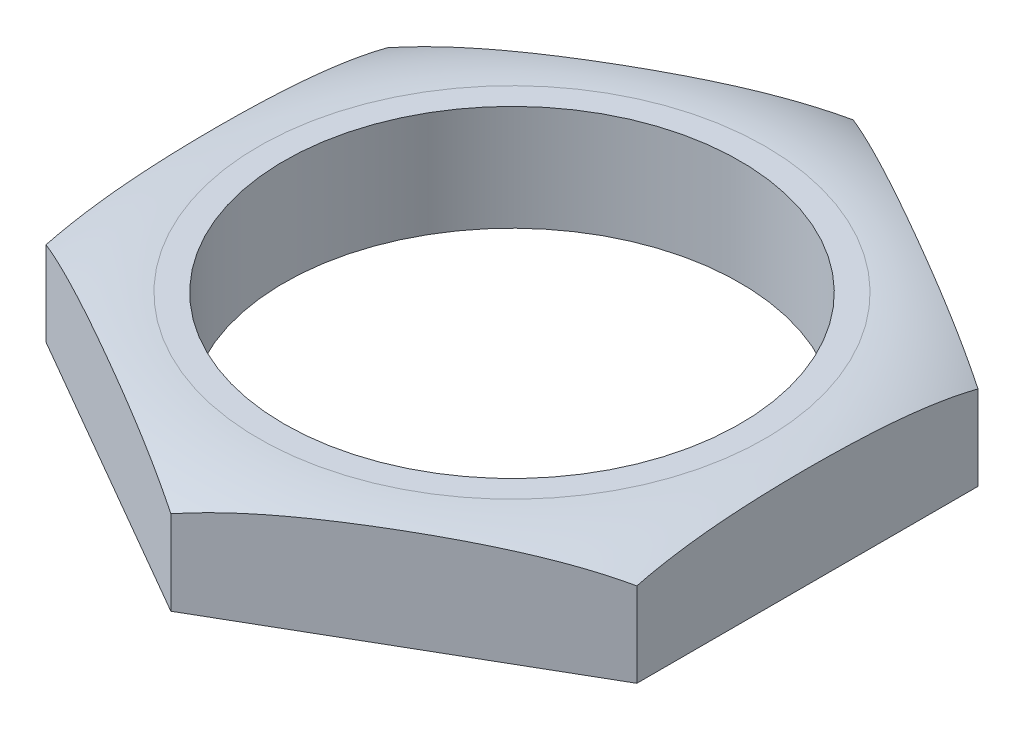
from build123d import *

# Parameters (mm, degrees)
EXTRUDE_1_DEPTH = 2.5
M12X1_252_D     = 10.8


with BuildPart() as part:
    # Эскиз1 → Бобышка-Вытянуть1 (new body)
    with BuildSketch(Plane(origin=(0, 0, 0), x_dir=(1, 0, 0), z_dir=(0, 1, 0))):
        Polygon((0, -8.082903769), (7, -4.041451884), (7, 4.041451884), (0, 8.082903769), (-7, 4.041451884), (-7, -4.041451884), align=None)
    extrude(amount=EXTRUDE_1_DEPTH)

    # Эскиз2 → Вырез-Повернуть1 (revolve, cut)
    with BuildSketch(Plane(origin=(0, 0, 0), x_dir=(0, 0, -1), z_dir=(1, 0, 0))):
        with BuildLine():
            Line((-8.082903769, 2.5), (-8.082903769, 2))
            ThreePointArc((-8.082903769, 2), (-7.071037827, 2.373249344), (-6, 2.5))
            Line((-6, 2.5), (-8.082903769, 2.5))
        make_face()
    revolve(axis=Axis((0, 0, 0), (0, 1, 0)), mode=Mode.SUBTRACT)

    # Отверстие обработанное метчиком M12x1.252 (through all)
    with Locations(Plane.ZX.offset(2.5)):
        with Locations((0, 0)):
            Hole(M12X1_252_D / 2)


solid = part.part
